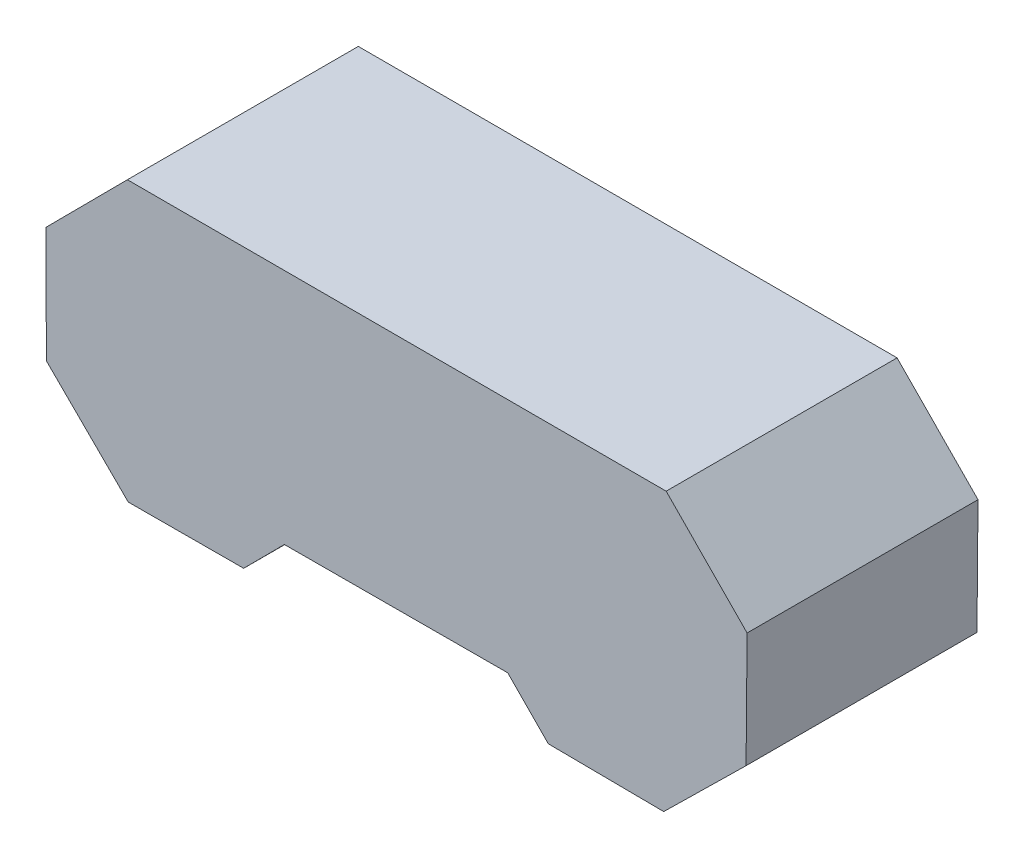
from build123d import *

# Parameters (mm, degrees)
BOSS_EXTRUDE1_DEPTH = 152.4


with BuildPart() as part:
    # Sketch1 → Boss-Extrude1 (new body)
    with BuildSketch(Plane.XY):
        Polygon((60.134584624, -64.442105219), (-87.319728788, -64.817872119), (-114.177945097, -91.84094035), (-190.38054091, -92.074085208), (-244.428771462, -38.355571274), (-244.66191632, 37.847024538), (-190.943402386, 91.895255091), (164.656597614, 91.673296873), (218.063811089, 37.317436895), (217.393016713, -38.882563105), (163.037156735, -92.28977658), (86.837156735, -91.618982204), align=None)
    extrude(amount=BOSS_EXTRUDE1_DEPTH)


solid = part.part
